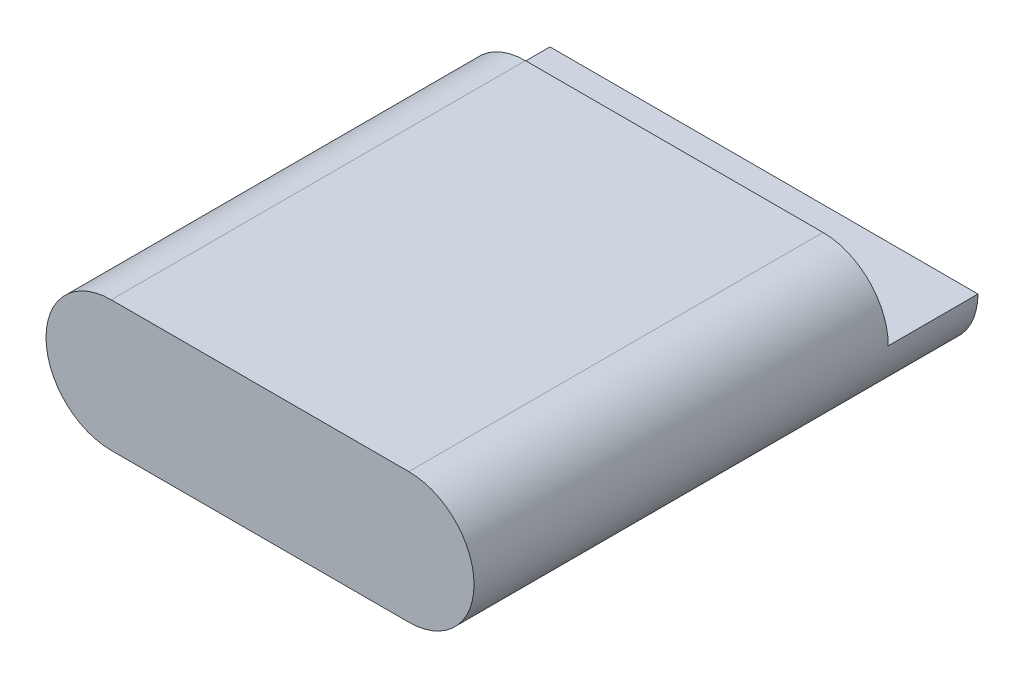
from build123d import *

# Parameters (mm, degrees)
BATTERY_BASE_DEPTH = 36.5
PINS_DEPTH         = 6.5


with BuildPart() as part:
    # Battery Base Sketch → Battery Base (new body)
    with BuildSketch(Plane.XY):
        with BuildLine():
            Line((-10.775, 4.725), (10.775, 4.725))
            ThreePointArc((10.775, 4.725), (15.5, 0), (10.775, -4.725))
            Line((10.775, -4.725), (-10.775, -4.725))
            ThreePointArc((-10.775, -4.725), (-15.5, 0), (-10.775, 4.725))
        make_face()
    extrude(amount=BATTERY_BASE_DEPTH)

    # Pins Sketch → Pins (cut)
    with BuildSketch(Plane(origin=(0, 0, 0), x_dir=(-1, 0, 0), z_dir=(0, 0, -1))):
        with BuildLine():
            Line((-15.499933862, -0.025), (15.499933862, -0.025))
            ThreePointArc((15.499933862, -0.025), (14.124906715, 3.332228984), (10.775, 4.725))
            Line((10.775, 4.725), (-10.775, 4.725))
            ThreePointArc((-10.775, 4.725), (-14.124906715, 3.332228984), (-15.499933862, -0.025))
        make_face()
    extrude(amount=-PINS_DEPTH, mode=Mode.SUBTRACT)


solid = part.part
